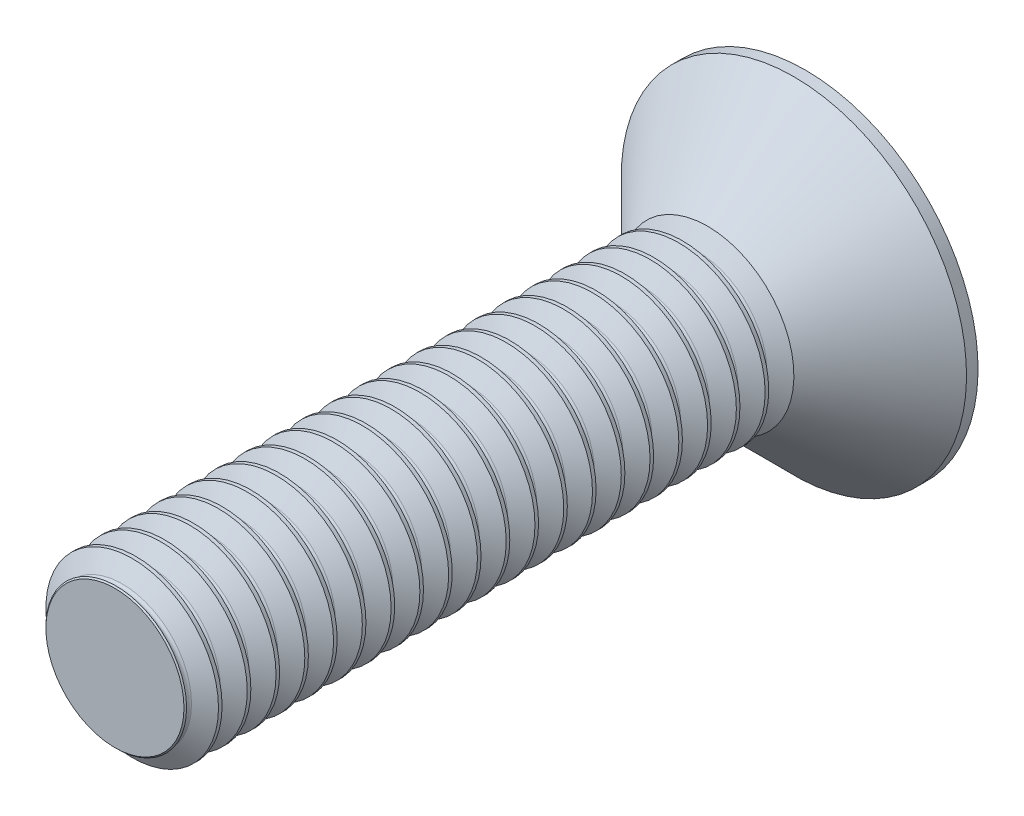
from build123d import *

# Parameters (mm, degrees)
SKETCH5_W           = 12
SKETCH5_H           = 1.5
THREAD_SIMPLE_COUNT = 21
THREAD_SIMPLE_PITCH = 0.5
SKETCH15_W          = 1.7
SKETCH15_H          = 3
CUT_HEAD_KEY_DEPTH  = 0.65


with BuildPart() as part:
    # Sketch5 → body (revolve)
    with BuildSketch(Plane(origin=(0, 0, 0), x_dir=(0, 0, -1), z_dir=(1, 0, 0))):
        with Locations((-6, 0.75)):
            Rectangle(SKETCH5_W, SKETCH5_H)
    revolve(axis=Axis((0, 0, 12), (0, 0, -1)))

    # Sketch11 → cut-chamfer-start (revolve, cut)
    with BuildSketch(Plane(origin=(0, 0, 0), x_dir=(0, 0, -1), z_dir=(1, 0, 0))):
        Polygon((-12, -1.5), (-12, -1.2), (-11.7, -1.5), align=None)
    revolve(axis=Axis((0, 0, 12), (0, 0, -1)), mode=Mode.SUBTRACT)

    # Sketch8 → thread-single (revolve, cut)
    with BuildSketch(Plane(origin=(0, 0, 0), x_dir=(0, 0, -1), z_dir=(1, 0, 0))):
        with BuildLine():
            Line((-2.1375, -1.5), (-1.7, -1.5))
            Line((-1.7, -1.5), (-1.871875, -1.202303767))
            ThreePointArc((-1.871875, -1.202303767), (-1.91875, -1.175240474), (-1.965625, -1.202303767))
            Line((-1.965625, -1.202303767), (-2.1375, -1.5))
        make_face()
    thread_single = revolve(axis=Axis((0, 0, 12), (0, 0, -1)), mode=Mode.SUBTRACT)

    # thread-simple: thread-single ×21
    with Locations(*[(0, 0, i * THREAD_SIMPLE_PITCH) for i in range(1, THREAD_SIMPLE_COUNT)]):
        add(thread_single, mode=Mode.SUBTRACT)

    # Sketch15 → body-head (revolve)
    with BuildSketch(Plane(origin=(0, 0, 0), x_dir=(0, 0, -1), z_dir=(1, 0, 0))):
        with Locations((-0.85, -1.5)):
            Rectangle(SKETCH15_W, SKETCH15_H)
    revolve(axis=Axis((0, 0, 0), (0, 0, 1)))

    # Sketch19 → cut-head-profile (revolve, cut)
    with BuildSketch(Plane(origin=(0, 0, 0), x_dir=(0, 0, -1), z_dir=(1, 0, 0))):
        Polygon((-1.7, -3.2), (-1.7, -1.5), (0, -3.2), align=None)
    revolve(axis=Axis((0, 0, 0), (0, 0, 1)), mode=Mode.SUBTRACT)

    # Sketch25 → cut-head-key (cut)
    with BuildSketch(Plane.XY):
        with BuildLine():
            ThreePointArc((0.182709695, 1.254833497), (0, 1.4), (-0.182709695, 1.254833497))
            ThreePointArc((-0.182709695, 1.254833497), (-0.487188951, 0.843836016), (-0.995362839, 0.785647986))
            ThreePointArc((-0.995362839, 0.785647986), (-1.212435565, 0.7), (-1.178072534, 0.469185512))
            ThreePointArc((-1.178072534, 0.469185512), (-0.974377901, 0), (-1.178072534, -0.469185512))
            ThreePointArc((-1.178072534, -0.469185512), (-1.212435565, -0.7), (-0.995362839, -0.785647986))
            ThreePointArc((-0.995362839, -0.785647986), (-0.487188951, -0.843836016), (-0.182709695, -1.254833497))
            ThreePointArc((-0.182709695, -1.254833497), (0, -1.4), (0.182709695, -1.254833497))
            ThreePointArc((0.182709695, -1.254833497), (0.487188951, -0.843836016), (0.995362839, -0.785647986))
            ThreePointArc((0.995362839, -0.785647986), (1.212435565, -0.7), (1.178072534, -0.469185512))
            ThreePointArc((1.178072534, -0.469185512), (0.974377901, 0), (1.178072534, 0.469185512))
            ThreePointArc((1.178072534, 0.469185512), (1.212435565, 0.7), (0.995362839, 0.785647986))
            ThreePointArc((0.995362839, 0.785647986), (0.487188951, 0.843836016), (0.182709695, 1.254833497))
        make_face()
    extrude(amount=CUT_HEAD_KEY_DEPTH, mode=Mode.SUBTRACT)


solid = part.part
